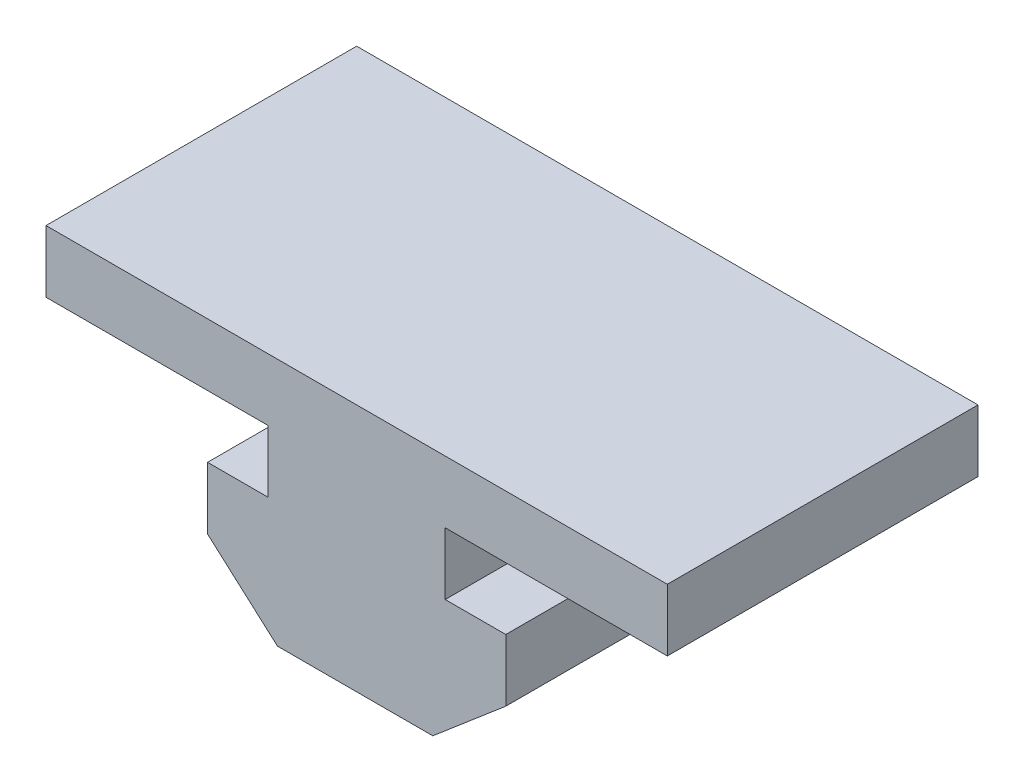
from build123d import *

# Parameters (mm, degrees)
BOSS_EXTRUDE1_DEPTH = 10


with BuildPart() as part:
    # Sketch2 → Boss-Extrude1 (new body)
    with BuildSketch(Plane.XY):
        Polygon((-2.5, -1.65), (2.5, -1.65), (4.85, 0.35), (4.85, 2.35), (2.9, 2.35), (2.9, 4.35), (10.05, 4.35), (10.05, 6.35), (-9.95, 6.35), (-9.95, 4.35), (-2.8, 4.35), (-2.8, 2.35), (-4.75, 2.35), (-4.75, 0.35), align=None)
    extrude(amount=BOSS_EXTRUDE1_DEPTH)


solid = part.part
